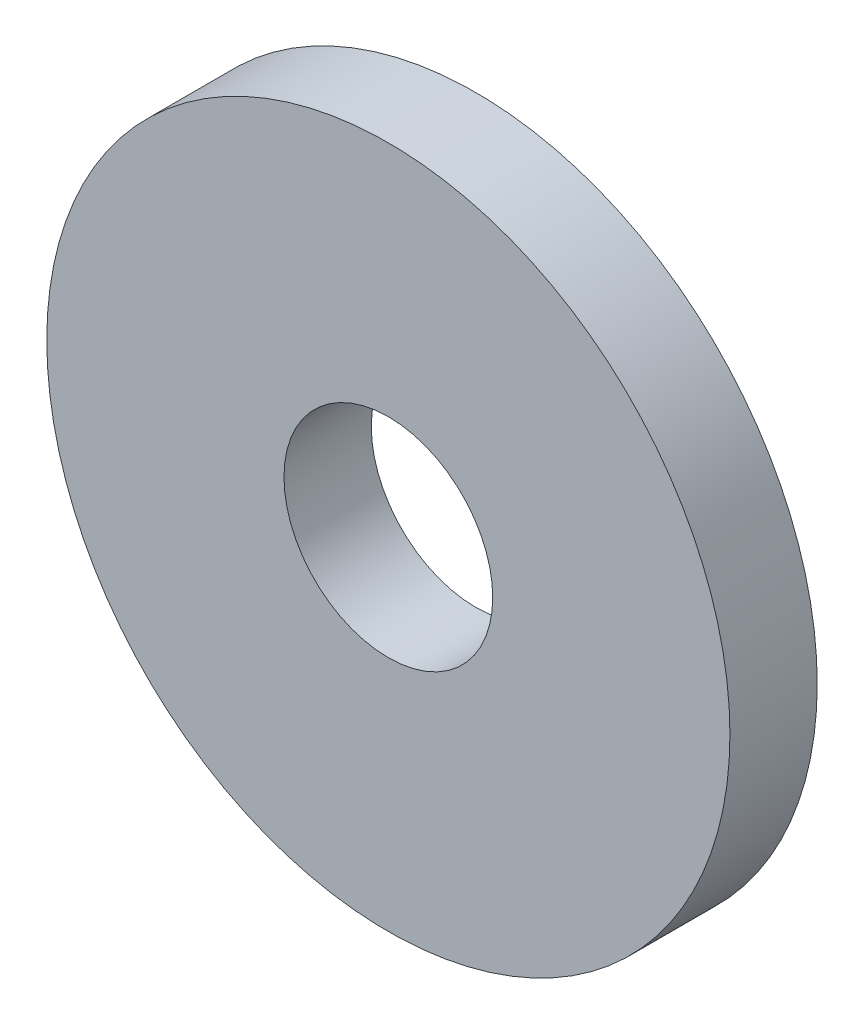
from build123d import *

# Parameters (mm, degrees)
SKETCH1_R           = 9
SKETCH1_R_2         = 2.75
BOSS_EXTRUDE1_DEPTH = 2.3


with BuildPart() as part:
    # Sketch1 → Boss-Extrude1 (new body)
    with BuildSketch(Plane.XY):
        Circle(SKETCH1_R)
        Circle(SKETCH1_R_2, mode=Mode.SUBTRACT)
    extrude(amount=BOSS_EXTRUDE1_DEPTH)


solid = part.part
